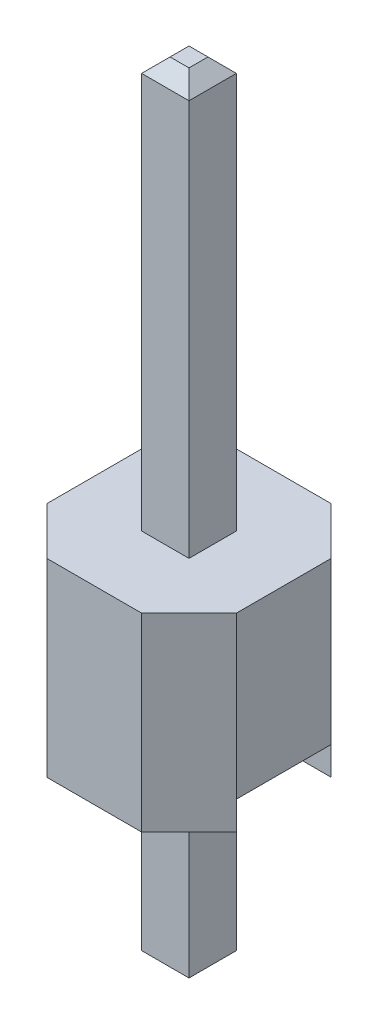
from build123d import *

# Parameters (mm, degrees)
BOSS_EXTRUDE1_DEPTH = 2.54
SKETCH2_W           = 1.27
SKETCH2_H           = 0.381
CUT_EXTRUDE1_DEPTH  = 2.54
SKETCH3_W           = 0.635
SKETCH3_H           = 0.635
BOSS_EXTRUDE2_DEPTH = 5.5
CHAMFER1_SIZE       = 0.1905
SKETCH4_W           = 0.635
SKETCH4_H           = 0.635
BOSS_EXTRUDE3_DEPTH = 2.9
CHAMFER2_SIZE       = 0.1905


with BuildPart() as part:
    # Sketch1 → Boss-Extrude1 (new body)
    with BuildSketch(Plane(origin=(0, 0, 0), x_dir=(1, 0, 0), z_dir=(0, 1, 0))):
        Polygon((0.635, 1.27), (1.27, 0.635), (1.27, -0.635), (0.635, -1.27), (-0.635, -1.27), (-1.27, -0.635), (-1.27, 0.635), (-0.635, 1.27), align=None)
    extrude(amount=BOSS_EXTRUDE1_DEPTH)

    # Sketch2 → Cut-Extrude1 (cut)
    with BuildSketch(Plane(origin=(1.27, 0, 0), x_dir=(0, 0, -1), z_dir=(1, 0, 0))):
        with Locations((0, 0.1905)):
            Rectangle(SKETCH2_W, SKETCH2_H)
    extrude(amount=-CUT_EXTRUDE1_DEPTH, mode=Mode.SUBTRACT)

    # Sketch3 → Boss-Extrude2 (add)
    with BuildSketch(Plane(origin=(0, 2.54, 0), x_dir=(1, 0, 0), z_dir=(0, 1, 0))):
        Rectangle(SKETCH3_W, SKETCH3_H)
    extrude(amount=BOSS_EXTRUDE2_DEPTH)

    # Chamfer1
    chamfer1_edges = [part.edges().sort_by_distance(p)[0] for p in [
        (0.3175, 8.04, 0),
        (0, 8.04, -0.3175),
        (-0.3175, 8.04, 0),
        (0, 8.04, 0.3175),
    ]]
    chamfer(chamfer1_edges, length=CHAMFER1_SIZE)

    # Sketch4 → Boss-Extrude3 (add)
    with BuildSketch(Plane.XZ.offset(-0.381)):
        Rectangle(SKETCH4_W, SKETCH4_H)
    extrude(amount=BOSS_EXTRUDE3_DEPTH)

    # Chamfer2
    chamfer2_edges = [part.edges().sort_by_distance(p)[0] for p in [
        (0.3175, -2.519, 0),
        (0, -2.519, 0.3175),
        (-0.3175, -2.519, 0),
        (0, -2.519, -0.3175),
    ]]
    chamfer(chamfer2_edges, length=CHAMFER2_SIZE)


solid = part.part
